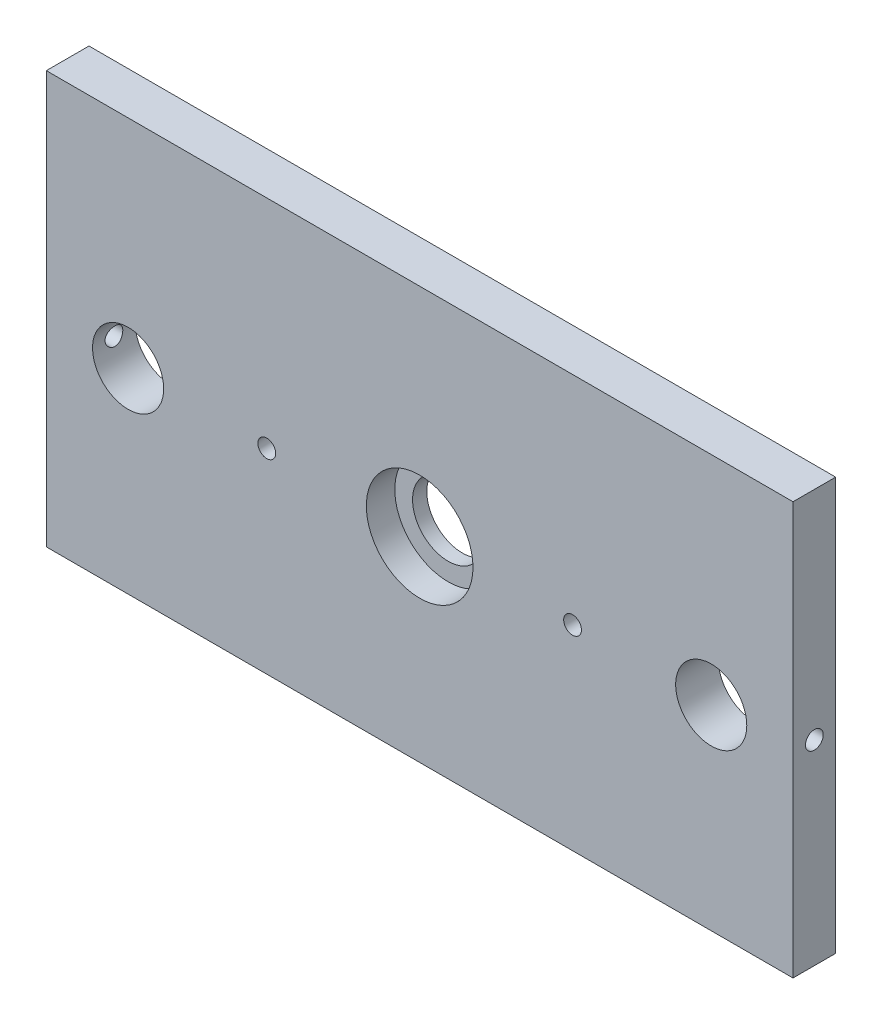
from build123d import *

# Parameters (mm, degrees)
SKETCH1_W                 = 210
SKETCH1_H                 = 12
BOSS_EXTRUDE1_DEPTH       = 116
SKETCH2_R                 = 10
CUT_EXTRUDE1_DEPTH        = 13
F_5_0MM_DOWEL_HOLE1_D     = 5
F_5_0MM_DOWEL_HOLE1_DEPTH = 25
F_5_0MM_DOWEL_HOLE1_TIP   = 1.502151548
F_5_0MM_DOWEL_HOLE2_D     = 5
F_5_0MM_DOWEL_HOLE2_DEPTH = 25
F_5_0MM_DOWEL_HOLE2_TIP   = 1.502151548
SKETCH7_R                 = 10
CUT_EXTRUDE2_DEPTH        = 13.0000001
SKETCH8_R                 = 15
CUT_EXTRUDE3_DEPTH        = 8
F_5_0MM_DOWEL_HOLE3_D     = 5
F_5_0MM_DOWEL_HOLE3_DEPTH = 12
F_5_0MM_DOWEL_HOLE3_TIP   = 1.502151548
F_5_0MM_DOWEL_HOLE4_D     = 5
F_5_0MM_DOWEL_HOLE4_DEPTH = 25
F_5_0MM_DOWEL_HOLE4_TIP   = 1.502151548


with BuildPart() as part:
    # Sketch1 → Boss-Extrude1 (new body)
    with BuildSketch(Plane(origin=(0, 0, 0), x_dir=(1, 0, 0), z_dir=(0, 1, 0))):
        with Locations((105, 6)):
            Rectangle(SKETCH1_W, SKETCH1_H)
    extrude(amount=BOSS_EXTRUDE1_DEPTH)

    # Sketch2 → Cut-Extrude1 (cut, through all)
    with BuildSketch(Plane.XY):
        with Locations((23, 55)):
            Circle(SKETCH2_R)
        with Locations((187, 55)):
            Circle(SKETCH2_R)
    extrude(amount=-CUT_EXTRUDE1_DEPTH, mode=Mode.SUBTRACT)

    # Ø5.0mm Dowel Hole1
    with Locations(Plane.ZY):
        with Locations((-6, 55)):
            Hole(F_5_0MM_DOWEL_HOLE1_D / 2, depth=F_5_0MM_DOWEL_HOLE1_DEPTH)
            with Locations((0, 0, -(F_5_0MM_DOWEL_HOLE1_DEPTH + F_5_0MM_DOWEL_HOLE1_TIP / 2))):  # 118° drill point
                Cone(0, F_5_0MM_DOWEL_HOLE1_D / 2, F_5_0MM_DOWEL_HOLE1_TIP, mode=Mode.SUBTRACT)

    # Ø5.0mm Dowel Hole2
    with Locations(Plane(origin=(210, 0, 0), x_dir=(0, 0, -1), z_dir=(1, 0, 0))):
        with Locations((6, 55)):
            Hole(F_5_0MM_DOWEL_HOLE2_D / 2, depth=F_5_0MM_DOWEL_HOLE2_DEPTH)
            with Locations((0, 0, -(F_5_0MM_DOWEL_HOLE2_DEPTH + F_5_0MM_DOWEL_HOLE2_TIP / 2))):  # 118° drill point
                Cone(0, F_5_0MM_DOWEL_HOLE2_D / 2, F_5_0MM_DOWEL_HOLE2_TIP, mode=Mode.SUBTRACT)

    # Sketch7 → Cut-Extrude2 (cut, through all)
    with BuildSketch(Plane.XY):
        with Locations((105, 55)):
            Circle(SKETCH7_R)
    extrude(amount=-CUT_EXTRUDE2_DEPTH, mode=Mode.SUBTRACT)

    # Sketch8 → Cut-Extrude3 (cut)
    with BuildSketch(Plane.XY):
        with Locations((105, 55)):
            Circle(SKETCH8_R)
    extrude(amount=-CUT_EXTRUDE3_DEPTH, mode=Mode.SUBTRACT)

    # Ø5.0mm Dowel Hole3
    with Locations(Plane(origin=(0, 0, 0), x_dir=(-1, 0, 0), z_dir=(0, -1, 0))):
        with Locations((-25, 6), (-105, 6), (-185, 6)):
            Hole(F_5_0MM_DOWEL_HOLE3_D / 2, depth=F_5_0MM_DOWEL_HOLE3_DEPTH)
            with Locations((0, 0, -(F_5_0MM_DOWEL_HOLE3_DEPTH + F_5_0MM_DOWEL_HOLE3_TIP / 2))):  # 118° drill point
                Cone(0, F_5_0MM_DOWEL_HOLE3_D / 2, F_5_0MM_DOWEL_HOLE3_TIP, mode=Mode.SUBTRACT)

    # Ø5.0mm Dowel Hole4
    with Locations(Plane(origin=(0, 0, -12), x_dir=(-1, 0, 0), z_dir=(0, 0, -1))):
        with Locations((-148, 55), (-62, 55)):
            Hole(F_5_0MM_DOWEL_HOLE4_D / 2, depth=F_5_0MM_DOWEL_HOLE4_DEPTH)
            with Locations((0, 0, -(F_5_0MM_DOWEL_HOLE4_DEPTH + F_5_0MM_DOWEL_HOLE4_TIP / 2))):  # 118° drill point
                Cone(0, F_5_0MM_DOWEL_HOLE4_D / 2, F_5_0MM_DOWEL_HOLE4_TIP, mode=Mode.SUBTRACT)


solid = part.part
